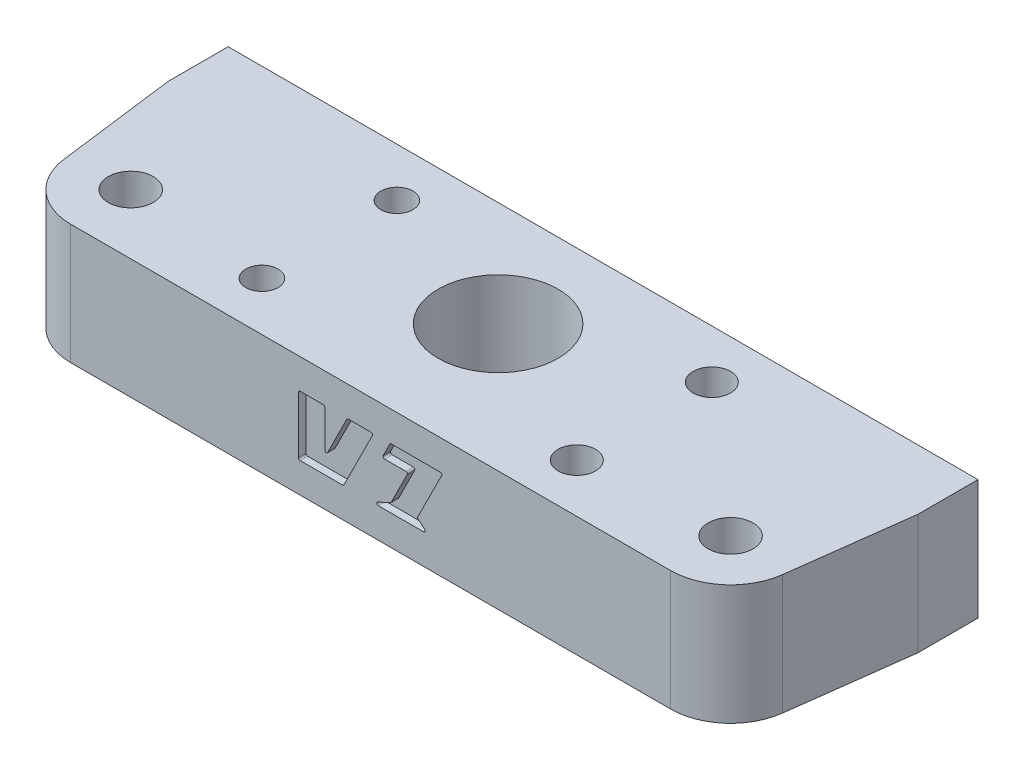
from build123d import *

# Parameters (mm, degrees)
SKETCH1_R           = 14
SKETCH1_R_2         = 5
BOSS_EXTRUDE1_DEPTH = 38
SKETCH2_R           = 8
SKETCH2_R_2         = 3
BOSS_EXTRUDE2_DEPTH = 16
SKETCH3_R           = 2.5
CUT_EXTRUDE1_DEPTH  = 21
SKETCH4_R           = 2.15
SKETCH4_R_2         = 2.5
CUT_EXTRUDE2_DEPTH  = 21
CUT_EXTRUDE3_DEPTH  = 1
FILLET2_R           = 0.2


with BuildPart() as part:
    # Sketch1 → Boss-Extrude1 (new body)
    with BuildSketch(Plane(origin=(0, 0, 0), x_dir=(1, 0, 0), z_dir=(0, 1, 0))):
        with BuildLine():
            Line((40, 57), (-40, 57))
            ThreePointArc((-40, 57), (-58.987886037, 46.111263827), (-59.17994648, 24.223653075))
            Line((-59.17994648, 24.223653075), (-47.255332989, 3))
            Line((-47.255332989, 3), (-32.311027529, 3))
            ThreePointArc((-32.311027529, 3), (32.415238263, -1.501608583), (-32.45, 0))
            Line((-32.45, 0), (-47.255332989, 0))
            Line((-47.255332989, 0), (-47.255332989, -10))
            Line((-47.255332989, -10), (-41.255332989, -10))
            ThreePointArc((-41.255332989, -10), (-4.643586709, -42.195255687), (38.093342034, -18.732319468))
            Line((38.093342034, -18.732319468), (59.742132503, 25.291848568))
            ThreePointArc((59.742132503, 25.291848568), (58.675911377, 46.627997861), (40, 57))
        make_face()
        with Locations((-40, 35)):
            Circle(SKETCH1_R, mode=Mode.SUBTRACT)
        with Locations((0, 44)):
            Circle(SKETCH1_R_2, mode=Mode.SUBTRACT)
        with Locations((40, 35)):
            Circle(SKETCH1_R, mode=Mode.SUBTRACT)
    extrude(amount=BOSS_EXTRUDE1_DEPTH)


with BuildPart() as body_2:
    # Sketch2 → Boss-Extrude2 (new body)
    with BuildSketch(Plane(origin=(0, 38, 0), x_dir=(1, 0, 0), z_dir=(0, 1, 0))):
        with BuildLine():
            Line((-40, 27), (40, 27))
            ThreePointArc((40, 27), (45.282843577, 28.992374534), (47.934336402, 33.977109066))
            Line((47.934336402, 33.977109066), (50, 50))
            Line((50, 50), (50, 58))
            Line((50, 58), (-50, 58))
            Line((-50, 58), (-50, 50))
            Line((-50, 50), (-47.934336402, 33.977109066))
            ThreePointArc((-47.934336402, 33.977109066), (-45.282843577, 28.992374534), (-40, 27))
        make_face()
        with Locations((0, 44)):
            Circle(SKETCH2_R, mode=Mode.SUBTRACT)
        with Locations((-40, 35)):
            Circle(SKETCH2_R_2, mode=Mode.SUBTRACT)
        with Locations((40, 35)):
            Circle(SKETCH2_R_2, mode=Mode.SUBTRACT)
    extrude(amount=BOSS_EXTRUDE2_DEPTH)

    # Sketch3 → Cut-Extrude1 (cut)
    with BuildSketch(Plane(origin=(0, 0, -58), x_dir=(-1, 0, 0), z_dir=(0, 0, -1))):
        with Locations((-40, 46)):
            Circle(SKETCH3_R)
        with Locations((40, 46)):
            Circle(SKETCH3_R)
    extrude(amount=-CUT_EXTRUDE1_DEPTH, mode=Mode.SUBTRACT)

    # Sketch4 → Cut-Extrude2 (cut)
    with BuildSketch(Plane.XZ.offset(-38)):
        with Locations((-21, -33.5)):
            Circle(SKETCH4_R)
        with Locations((-21, -51.5)):
            Circle(SKETCH4_R)
        with Locations((21, -51.5)):
            Circle(SKETCH4_R_2)
        with Locations((21, -33.5)):
            Circle(SKETCH4_R_2)
    extrude(amount=-CUT_EXTRUDE2_DEPTH, mode=Mode.SUBTRACT)

    # Sketch6 → Cut-Extrude3 (cut)
    with BuildSketch(Plane.XY.offset(-27)):
        Polygon((-6.118033989, 44), (-6.118033989, 50), (-9.618033989, 50), (-9.618033989, 42), (-3.618033989, 42), (0.381966011, 50), (-3.118033989, 50), align=None)
        Polygon((9.618033989, 50), (2.618033989, 50), (1.518033989, 47.8), (5.018033989, 47.8), (2.718033989, 43.2), (0.118033989, 42), (2.118033989, 42), (5.618033989, 42), (7.618033989, 42), (6.218033989, 43.2), align=None)
    extrude(amount=-CUT_EXTRUDE3_DEPTH, mode=Mode.SUBTRACT)

    # Fillet2
    fillet2_edges = [body_2.edges().sort_by_distance(p)[0] for p in [
        (7.618033989, 42, -27.5),
        (0.118033989, 42, -27.5),
        (2.718033989, 43.2, -27.5),
        (5.018033989, 47.8, -27.5),
        (1.518033989, 47.8, -27.5),
        (2.618033989, 50, -27.5),
        (9.618033989, 50, -27.5),
        (6.218033989, 43.2, -27.5),
        (-6.118033989, 50, -27.5),
        (-6.118033989, 44, -27.5),
        (-3.118033989, 50, -27.5),
        (0.381966011, 50, -27.5),
        (-3.618033989, 42, -27.5),
        (-9.618033989, 42, -27.5),
        (-9.618033989, 50, -27.5),
    ]]
    fillet(fillet2_edges, radius=FILLET2_R)


solid = body_2.part
